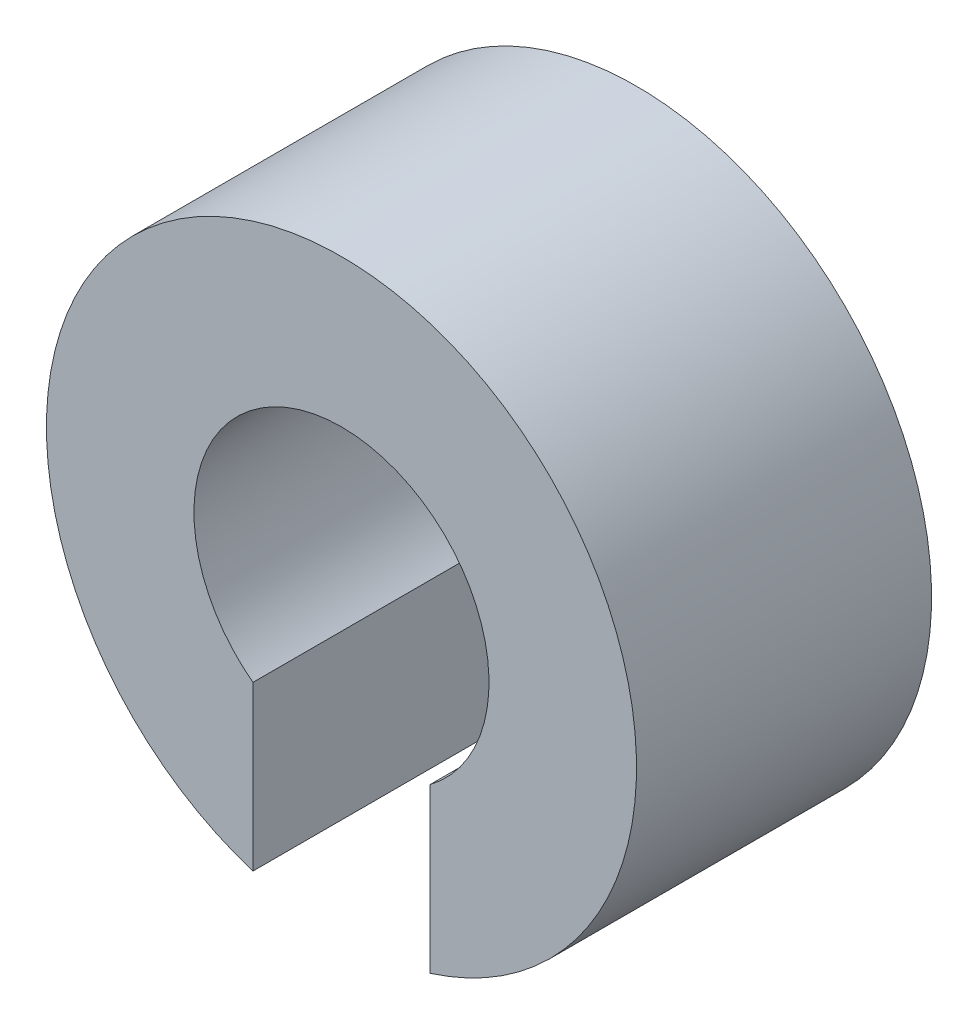
from build123d import *

# Parameters (mm, degrees)
EXTRUDE_1_DEPTH = 5


with BuildPart() as part:
    # ｽｹｯﾁ1 → ﾎﾞｽ - 押し出し1 (new body)
    with BuildSketch(Plane.XY):
        with BuildLine():
            Line((-1.5, -4.769696007), (-1.5, -2))
            ThreePointArc((-1.5, -2), (0, 2.5), (1.5, -2))
            Line((1.5, -2), (1.5, -4.769696007))
            ThreePointArc((1.5, -4.769696007), (0, 5), (-1.5, -4.769696007))
        make_face()
    extrude(amount=EXTRUDE_1_DEPTH)


solid = part.part
